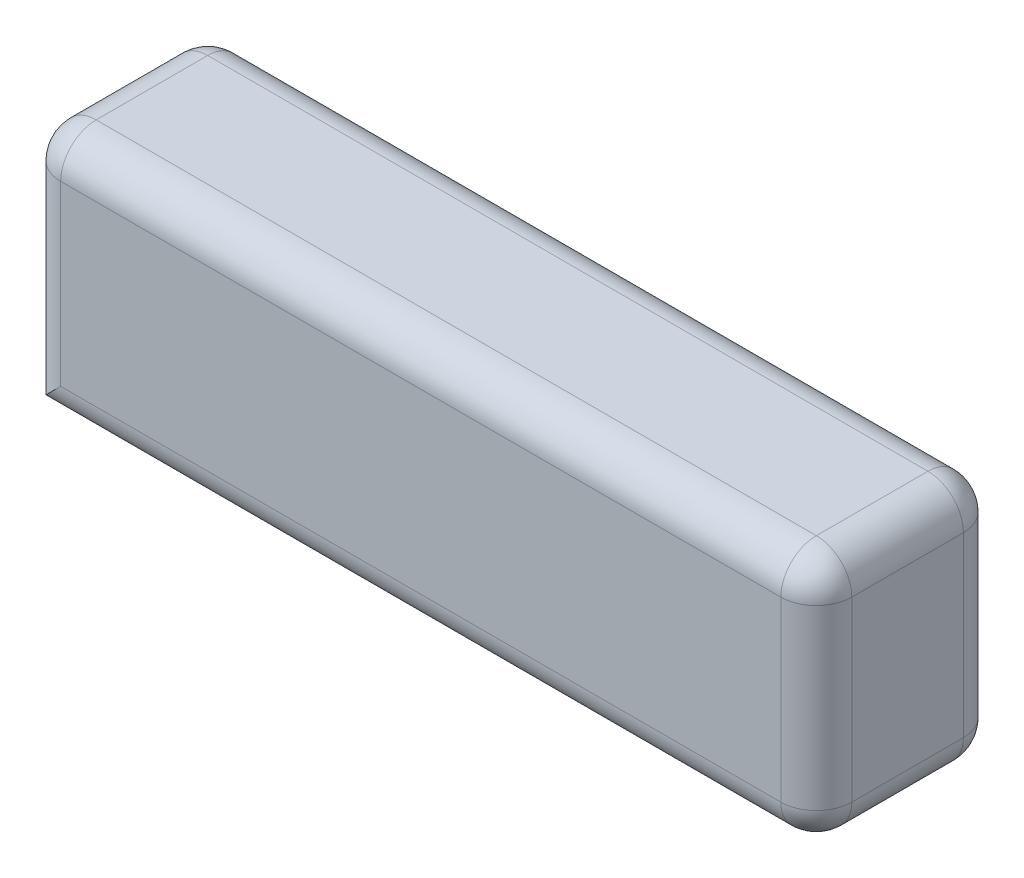
from build123d import *

# Parameters (mm, degrees)
SKETCH1_W           = 156
SKETCH1_H           = 49
BOSS_EXTRUDE1_DEPTH = 36
FILLET1_R           = 7


with BuildPart() as part:
    # Sketch1 → Boss-Extrude1 (new body)
    with BuildSketch(Plane.XY):
        with Locations((78, 24.5)):
            Rectangle(SKETCH1_W, SKETCH1_H)
    extrude(amount=BOSS_EXTRUDE1_DEPTH)

    # Fillet1
    fillet1_edges = [part.edges().sort_by_distance(p)[0] for p in [
        (156, 24.5, 36),
        (78, 49, 36),
        (0, 24.5, 36),
        (78, 49, 0),
        (156, 24.5, 0),
        (78, 0, 0),
        (0, 24.5, 0),
        (78, 0, 36),
        (0, 49, 18),
        (156, 49, 18),
        (156, 0, 18),
    ]]
    fillet(fillet1_edges, radius=FILLET1_R)


solid = part.part
